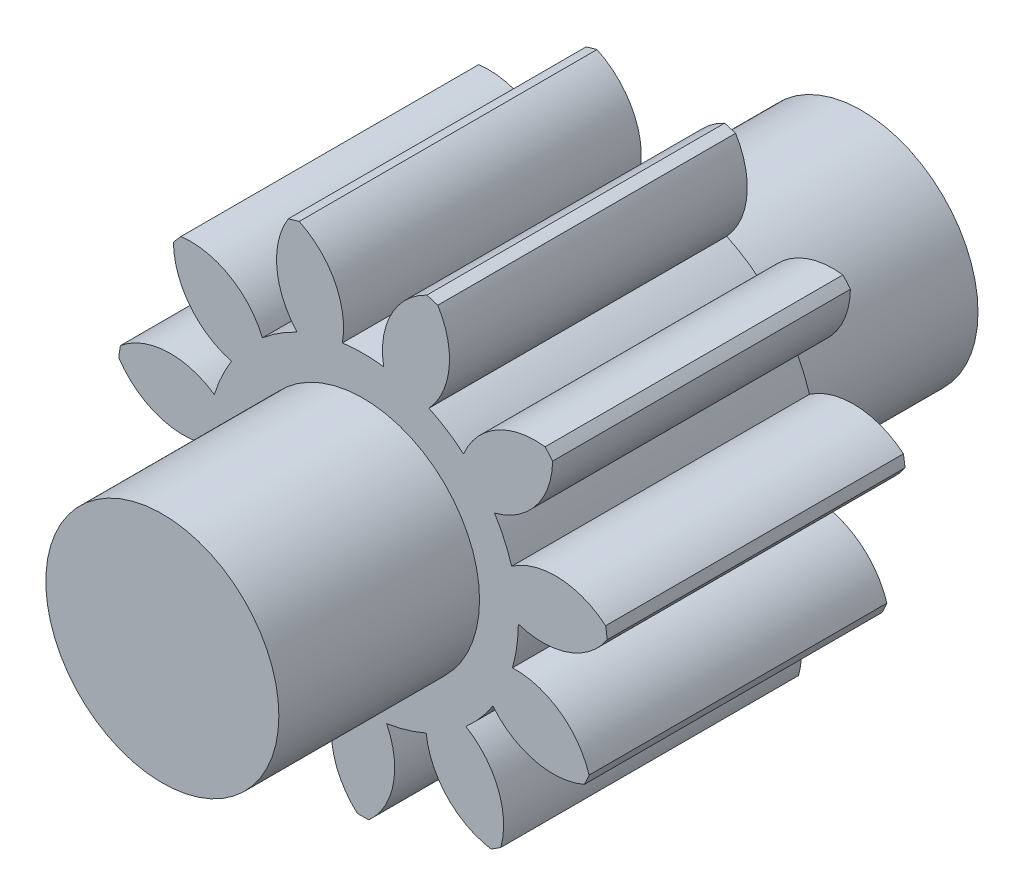
from build123d import *

# Parameters (mm, degrees)
SKETCH1_R           = 9
BOSS_EXTRUDE1_DEPTH = 27
BOSS_EXTRUDE2_DEPTH = 11.5


with BuildPart() as part:
    # Sketch1 → Boss-Extrude1 (new body, symmetric)
    with BuildSketch(Plane.XY):
        Circle(SKETCH1_R)
    extrude(amount=BOSS_EXTRUDE1_DEPTH, both=True)

    # Sketch2 → Boss-Extrude2 (add, symmetric)
    with BuildSketch(Plane.XY):
        with BuildLine():
            ThreePointArc((1.592403849, 11.893874473), (0, 12), (-1.592403849, 11.893874473))
            ThreePointArc((-1.592403849, 11.893874473), (-2.170910027, 15.684139908), (-4.926417678, 18.350215499))
            ThreePointArc((-4.926417678, 18.350215499), (-5.35291858, 18.230366499), (-5.776509232, 18.100606097))
            ThreePointArc((-5.776509232, 18.100606097), (-6.653200491, 14.368020679), (-5.090698654, 10.866682438))
            ThreePointArc((-5.090698654, 10.866682438), (-6.487689809, 10.095042394), (-7.769929381, 9.144845401))
            ThreePointArc((-7.769929381, 9.144845401), (-10.305771951, 12.020655535), (-14.065241784, 12.773761136))
            ThreePointArc((-14.065241784, 12.773761136), (-14.359241913, 12.442353945), (-14.645435276, 12.104182152))
            ThreePointArc((-14.645435276, 12.104182152), (-13.364966863, 8.490156404), (-10.157540304, 6.389395509))
            ThreePointArc((-10.157540304, 6.389395509), (-10.915583944, 4.984980156), (-11.480557235, 3.492392528))
            ThreePointArc((-11.480557235, 3.492392528), (-15.168624097, 4.540697964), (-18.738451003, 3.141727868))
            ThreePointArc((-18.738451003, 3.141727868), (-18.806607396, 2.703981927), (-18.864539099, 2.264765898))
            ThreePointArc((-18.864539099, 2.264765898), (-15.833450688, -0.083272541), (-11.999434677, -0.116479348))
            ThreePointArc((-11.999434677, -0.116479348), (-11.877857303, -1.707778059), (-11.546189284, -3.268870296))
            ThreePointArc((-11.546189284, -3.268870296), (-15.215545269, -4.380899128), (-17.462334429, -7.4877818))
            ThreePointArc((-17.462334429, -7.4877818), (-17.283007912, -7.892885247), (-17.094285049, -8.293697527))
            ThreePointArc((-17.094285049, -8.293697527), (-13.274925794, -8.630263043), (-10.031593324, -6.585372836))
            ThreePointArc((-10.031593324, -6.585372836), (-9.068994892, -7.858328807), (-7.945987817, -8.992289898))
            ThreePointArc((-7.945987817, -8.992289898), (-10.431638326, -11.911591701), (-10.642050057, -15.739973653))
            ThreePointArc((-10.642050057, -15.739973653), (-10.272175532, -15.983817124), (-9.896716278, -16.218970587))
            ThreePointArc((-9.896716278, -16.218970587), (-6.501705756, -14.437206007), (-4.87879197, -10.963456978))
            ThreePointArc((-4.87879197, -10.963456978), (-3.380790682, -11.513915683), (-1.822991362, -11.860720994))
            ThreePointArc((-1.822991362, -11.860720994), (-2.335759921, -15.660438072), (-0.442989984, -18.994835084))
            ThreePointArc((-0.442989984, -18.994835084), (0, -19), (0.442989984, -18.994835084))
            ThreePointArc((0.442989984, -18.994835084), (2.335759921, -15.660438072), (1.822991362, -11.860720994))
            ThreePointArc((1.822991362, -11.860720994), (3.380790682, -11.513915683), (4.87879197, -10.963456978))
            ThreePointArc((4.87879197, -10.963456978), (6.501705756, -14.437206007), (9.896716278, -16.218970587))
            ThreePointArc((9.896716278, -16.218970587), (10.272175532, -15.983817124), (10.642050057, -15.739973653))
            ThreePointArc((10.642050057, -15.739973653), (10.431638326, -11.911591701), (7.945987817, -8.992289898))
            ThreePointArc((7.945987817, -8.992289898), (9.068994892, -7.858328807), (10.031593324, -6.585372836))
            ThreePointArc((10.031593324, -6.585372836), (13.274925794, -8.630263043), (17.094285049, -8.293697527))
            ThreePointArc((17.094285049, -8.293697527), (17.283007912, -7.892885247), (17.462334429, -7.4877818))
            ThreePointArc((17.462334429, -7.4877818), (15.215545269, -4.380899128), (11.546189284, -3.268870296))
            ThreePointArc((11.546189284, -3.268870296), (11.877857303, -1.707778059), (11.999434677, -0.116479348))
            ThreePointArc((11.999434677, -0.116479348), (15.833450688, -0.083272541), (18.864539099, 2.264765898))
            ThreePointArc((18.864539099, 2.264765898), (18.806607396, 2.703981927), (18.738451003, 3.141727868))
            ThreePointArc((18.738451003, 3.141727868), (15.168624097, 4.540697964), (11.480557235, 3.492392528))
            ThreePointArc((11.480557235, 3.492392528), (10.915583944, 4.984980156), (10.157540304, 6.389395509))
            ThreePointArc((10.157540304, 6.389395509), (13.364966863, 8.490156404), (14.645435276, 12.104182152))
            ThreePointArc((14.645435276, 12.104182152), (14.359241913, 12.442353945), (14.065241784, 12.773761136))
            ThreePointArc((14.065241784, 12.773761136), (10.305771951, 12.020655535), (7.769929381, 9.144845401))
            ThreePointArc((7.769929381, 9.144845401), (6.487689809, 10.095042394), (5.090698654, 10.866682438))
            ThreePointArc((5.090698654, 10.866682438), (6.653200491, 14.368020679), (5.776509232, 18.100606097))
            ThreePointArc((5.776509232, 18.100606097), (5.35291858, 18.230366499), (4.926417678, 18.350215499))
            ThreePointArc((4.926417678, 18.350215499), (2.170910027, 15.684139908), (1.592403849, 11.893874473))
        make_face()
    extrude(amount=BOSS_EXTRUDE2_DEPTH, both=True)


solid = part.part
